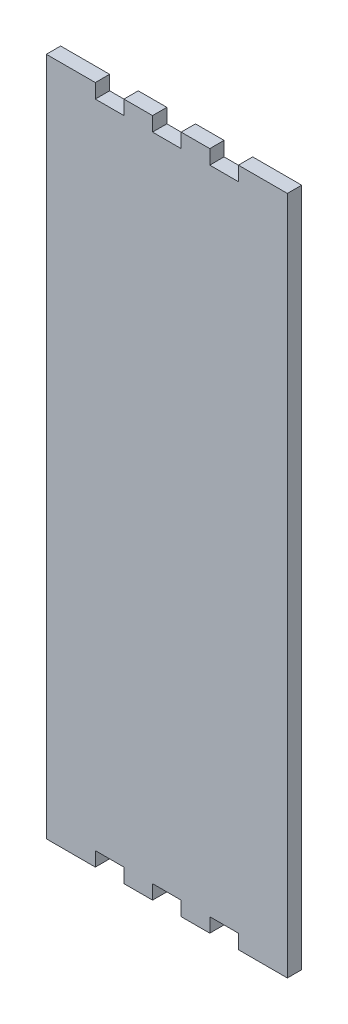
from build123d import *

# Parameters (mm, degrees)
BOSS_EXTRUDE1_DEPTH = 5.715


with BuildPart() as part:
    # Model → Boss-Extrude1 (new body)
    with BuildSketch(Plane.XY):
        Polygon((980.65387555, 22.860238699), (994.504678765, 22.860238699), (994.504678765, 28.575245224), (1005.935400477, 28.575245224), (1005.935400477, 22.860238699), (1017.36612219, 22.860238699), (1017.36612219, 28.575245224), (1028.796843902, 28.575245224), (1028.796843902, 22.860238699), (1040.224022303, 22.860238699), (1040.224022303, 28.575245224), (1051.654744015, 28.575245224), (1051.654744015, 22.860238699), (1065.509090542, 22.860238699), (1071.220908087, 22.860238699), (1071.220908087, 28.575245224), (1071.220908087, 288.575408216), (1071.220908087, 294.290414741), (1065.509090542, 294.290414741), (1051.654744015, 294.290414741), (1051.654744015, 288.575408216), (1040.224022303, 288.575408216), (1040.224022303, 294.290414741), (1028.796843902, 294.290414741), (1028.796843902, 288.575408216), (1017.36612219, 288.575408216), (1017.36612219, 294.290414741), (1005.935400477, 294.290414741), (1005.935400477, 288.575408216), (994.504678765, 288.575408216), (994.504678765, 294.290414741), (980.65387555, 294.290414741), (974.938514694, 294.290414741), (974.938514694, 288.575408216), (974.938514694, 28.575245224), (974.938514694, 22.860238699), align=None)
    extrude(amount=BOSS_EXTRUDE1_DEPTH)


solid = part.part
